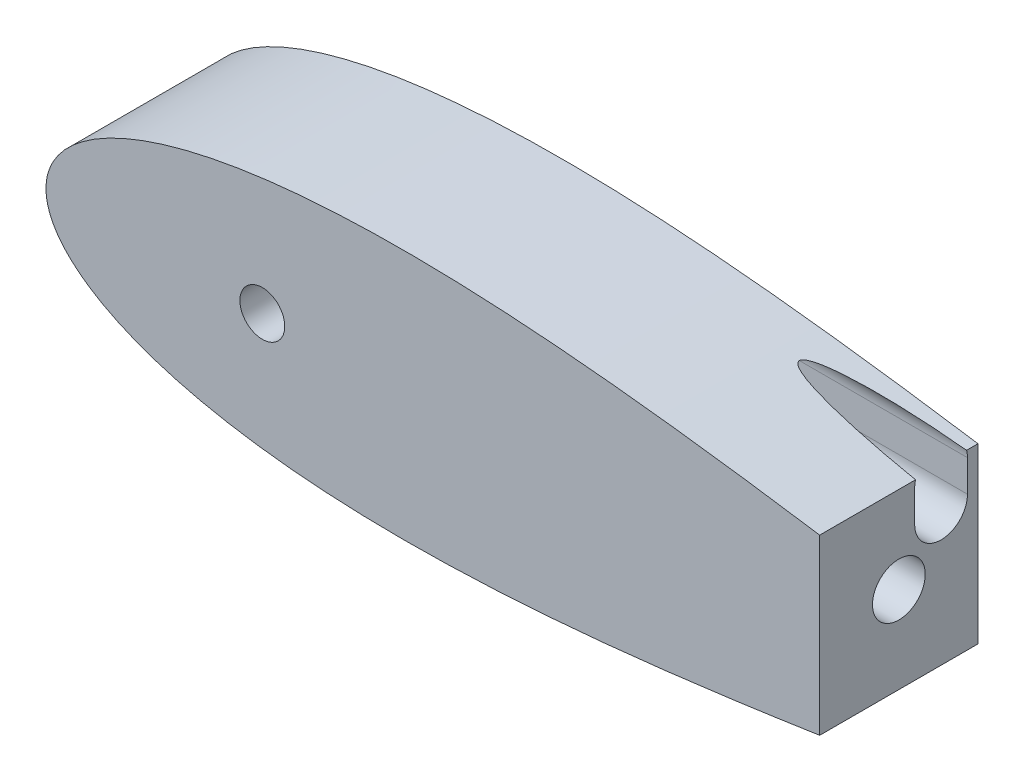
from build123d import *

# Parameters (mm, degrees)
BOSS_EXTRUDE1_DEPTH     = 76.2
SKETCH3_R               = 10.795
CUT_EXTRUDE2_DEPTH      = 76.2
SKETCH6_R               = 6.35
CUT_EXTRUDE3_DEPTH      = 53.34
CUT_EXTRUDE3_DEPTH_BACK = 0.000254
SKETCH7_R               = 1.5875
CUT_EXTRUDE4_DEPTH      = 30.48
SKETCH8_W               = 304.8
SKETCH8_H               = 127
CUT_EXTRUDE5_DEPTH      = 76.2
SKETCH9_R               = 12.7
CUT_EXTRUDE6_DEPTH      = 101.6
SKETCH10_R              = 3.175
CUT_EXTRUDE7_DEPTH      = 57.15
SKETCH11_R              = 5.08
CUT_EXTRUDE8_DEPTH      = 6.35
SKETCH12_R              = 3.175
CUT_EXTRUDE9_DEPTH      = 6.35
CUT_EXTRUDE10_DEPTH     = 198.458047838


with BuildPart() as part:
    # Sketch1 → Boss-Extrude1 (new body)
    with BuildSketch(Plane.XY):
        with BuildLine():
            Line((643.966787522, 0), (643.599082689, 0))
            Line((643.599082689, 0), (643.599082689, -1.016))
            ThreePointArc((643.599082689, -1.016), (643.872033494, -0.540245973), (643.966787522, 0))
        make_face()
        with BuildLine():
            Line((643.599082689, -1.016), (643.599082689, 0))
            Line((643.599082689, 0), (641.567082689, 0))
            ThreePointArc((641.567082689, 0), (642.269121423, -1.135922533), (643.599082689, -1.016))
        make_face()
        with BuildLine():
            Line((641.567082689, 0), (643.599082689, 0))
            Line((643.599082689, 0), (643.966787522, 0))
            ThreePointArc((643.966787522, 0), (643.547407924, 1.075012082), (642.510849283, 1.582039112))
            add(Edge.make_bspline(
                [(642.510849283, 1.582039112), (641.993392355, 1.625070631), (638.093728429, 1.953546407), (630.413817462, 2.663385493), (619.014124193, 3.849253664), (606.374988512, 5.304428983), (592.543922516, 7.037634907), (577.585454095, 9.050636147), (561.564270734, 11.338919625), (544.549749946, 13.890665375), (526.614143658, 16.687720753), (507.832591566, 19.705111663), (488.282710288, 22.911672601), (468.044367735, 26.27043606), (447.199424328, 29.739007432), (425.831595832, 33.270324121), (404.02631566, 36.813220545), (381.870662856, 40.313266856), (359.453314895, 43.713502532), (336.86454415, 46.955447457), (314.196207315, 49.979843895), (291.541767704, 52.727712704), (268.996310773, 55.141201012), (246.65655865, 57.164603829), (224.620860897, 58.745176641), (202.989192599, 59.8341217), (181.863132616, 60.387506142), (161.345829027, 60.366961324), (141.542033828, 59.739895824), (122.558104573, 58.481758104), (104.502313427, 56.574303932), (87.485018636, 54.008935199), (71.619696083, 50.784752003), (57.023709725, 46.912543066), (43.82045433, 42.41500246), (32.141645239, 37.332204029), (22.129107375, 31.731455339), (13.932423524, 25.726412106), (7.689616489, 19.513207632), (3.463136343, 13.420354421), (1.106333228, 7.923389435), (0.154611582, 3.513796615), (0, 1.007496172), (0, 0)],
                knots=[0.020157042, 0.020157042, 0.020157042, 0.020157042, 0.021270888, 0.028552555, 0.036780684, 0.045920102, 0.055931764, 0.066772884, 0.07839713, 0.090754827, 0.103793165, 0.117456432, 0.131686226, 0.146421738, 0.161599998, 0.177156133, 0.193023668, 0.209134786, 0.225420633, 0.241811602, 0.258237647, 0.274628557, 0.290914287, 0.307025229, 0.322892517, 0.338448342, 0.353626207, 0.368361232, 0.382590428, 0.396252961, 0.409290412, 0.42164701, 0.433269881, 0.444109249, 0.45411864, 0.463255055, 0.471479114, 0.478755289, 0.485052318, 0.490344026, 0.494609833, 0.497833231, 0.5, 0.5, 0.5, 0.5], degree=3))
            Line((0, 0), (27.94, 0))
            ThreePointArc((27.94, 0), (40.64, 12.7), (53.34, 0))
            Line((53.34, 0), (93.345, 0))
            ThreePointArc((93.345, 0), (104.14, 10.795), (114.935, 0))
            Line((114.935, 0), (460.660965279, 0))
            Line((460.660965279, 0), (473.360965279, 0))
            Line((473.360965279, 0), (641.567082689, 0))
        make_face()
        with BuildLine():
            ThreePointArc((642.510849283, -1.582039112), (643.111845681, -1.408373102), (643.599082689, -1.016))
            ThreePointArc((643.599082689, -1.016), (642.269121423, -1.135922533), (641.567082689, 0))
            Line((641.567082689, 0), (473.360965279, 0))
            Line((473.360965279, 0), (460.660965279, 0))
            Line((460.660965279, 0), (114.935, 0))
            ThreePointArc((114.935, 0), (104.14, -10.795), (93.345, 0))
            Line((93.345, 0), (53.34, 0))
            ThreePointArc((53.34, 0), (40.64, -12.7), (27.94, 0))
            Line((27.94, 0), (0, 0))
            add(Edge.make_bspline(
                [(0, 0), (0, -1.007496172), (0.154611582, -3.513796615), (1.106333228, -7.923389435), (3.463136343, -13.420354421), (7.689616489, -19.513207632), (13.932423524, -25.726412106), (22.129107375, -31.731455339), (32.141645239, -37.332204029), (43.82045433, -42.41500246), (57.023709725, -46.912543066), (71.619696083, -50.784752003), (87.485018636, -54.008935199), (104.502313427, -56.574303932), (122.558104573, -58.481758104), (141.542033828, -59.739895824), (161.345829027, -60.366961324), (181.863132616, -60.387506142), (202.989192599, -59.8341217), (224.620860897, -58.745176641), (246.65655865, -57.164603829), (268.996310773, -55.141201012), (291.541767704, -52.727712704), (314.196207315, -49.979843895), (336.86454415, -46.955447457), (359.453314895, -43.713502532), (381.870662856, -40.313266856), (404.02631566, -36.813220545), (425.831595832, -33.270324121), (447.199424328, -29.739007432), (468.044367735, -26.27043606), (488.282710288, -22.911672601), (507.832591566, -19.705111663), (526.614143658, -16.687720753), (544.549749946, -13.890665375), (561.564270734, -11.338919625), (577.585454095, -9.050636147), (592.543922516, -7.037634907), (606.374988512, -5.304428983), (619.014124193, -3.849253664), (630.413817462, -2.663385493), (638.093728429, -1.953546407), (641.993392355, -1.625070631), (642.510849283, -1.582039112)],
                knots=[0.5, 0.5, 0.5, 0.5, 0.502166769, 0.505390167, 0.509655974, 0.514947682, 0.521244711, 0.528520886, 0.536744945, 0.54588136, 0.555890751, 0.566730119, 0.57835299, 0.590709588, 0.603747039, 0.617409572, 0.631638768, 0.646373793, 0.661551658, 0.677107483, 0.692974771, 0.709085713, 0.725371443, 0.741762353, 0.758188398, 0.774579367, 0.790865214, 0.806976332, 0.822843867, 0.838400002, 0.853578262, 0.868313774, 0.882543568, 0.896206835, 0.909245173, 0.92160287, 0.933227116, 0.944068236, 0.954079898, 0.963219316, 0.971447445, 0.978729112, 0.979842958, 0.979842958, 0.979842958, 0.979842958], degree=3))
        make_face()
        with BuildLine():
            ThreePointArc((643.966787522, 0), (643.872033494, -0.540245973), (643.599082689, -1.016))
            ThreePointArc((643.599082689, -1.016), (643.111845681, -1.408373102), (642.510849283, -1.582039112))
            add(Edge.make_bspline(
                [(642.510849283, -1.582039112), (644.922074617, -1.381522545), (649.798936594, -1.000308437), (656.504964311, -0.543558383), (662.850933168, -0.234427605), (666.344759683, -0.054696708), (670.56, -0.015678595), (670.56, 0)],
                knots=[0.979842958, 0.979842958, 0.979842958, 0.979842958, 0.985033212, 0.990332793, 0.994605218, 0.997832222, 1, 1, 1, 1], degree=3))
            add(Edge.make_bspline(
                [(670.56, 0), (670.56, 0.015678595), (666.344759683, 0.054696708), (662.850933168, 0.234427605), (656.504964311, 0.543558383), (649.798936594, 1.000308437), (644.922074617, 1.381522545), (642.510849283, 1.582039112)],
                knots=[0, 0, 0, 0, 0.002167778, 0.005394782, 0.009667207, 0.014966788, 0.020157042, 0.020157042, 0.020157042, 0.020157042], degree=3))
            ThreePointArc((642.510849283, 1.582039112), (643.547407924, 1.075012082), (643.966787522, 0))
        make_face()
        with BuildLine():
            ThreePointArc((53.34, 0), (40.64, 12.7), (27.94, 0))
            Line((27.94, 0), (53.34, 0))
        make_face()
        with BuildLine():
            Line((53.34, 0), (27.94, 0))
            ThreePointArc((27.94, 0), (40.64, -12.7), (53.34, 0))
        make_face()
        with BuildLine():
            ThreePointArc((93.345, 0), (104.14, -10.795), (114.935, 0))
            Line((114.935, 0), (93.345, 0))
        make_face()
        with BuildLine():
            Line((93.345, 0), (114.935, 0))
            ThreePointArc((114.935, 0), (104.14, 10.795), (93.345, 0))
        make_face()
    extrude(amount=BOSS_EXTRUDE1_DEPTH)

    # Sketch3 → Cut-Extrude2 (cut)
    with BuildSketch(Plane.XY.offset(76.2)):
        with Locations((104.139232412, 0)):
            Circle(SKETCH3_R)
    extrude(amount=-CUT_EXTRUDE2_DEPTH, mode=Mode.SUBTRACT)

    # Sketch6 → Cut-Extrude3 (cut, two sides)
    with BuildSketch(Plane(origin=(0, 0, 0), x_dir=(0, 0, -1), z_dir=(1, 0, 0))) as cut_extrude3_sk:
        with Locations((-20.32, 0)):
            Circle(SKETCH6_R)
    extrude(amount=CUT_EXTRUDE3_DEPTH, mode=Mode.SUBTRACT)
    extrude(cut_extrude3_sk.sketch, amount=-CUT_EXTRUDE3_DEPTH_BACK, mode=Mode.SUBTRACT)

    # Sketch7 → Cut-Extrude4 (cut)
    with BuildSketch(Plane(origin=(0, 0, 0), x_dir=(-1, 0, 0), z_dir=(0, 0, -1))):
        with Locations((-38.1, 0)):
            Circle(SKETCH7_R)
        with Locations((-50.8, 0)):
            Circle(SKETCH7_R)
    extrude(amount=-CUT_EXTRUDE4_DEPTH, mode=Mode.SUBTRACT)

    # Sketch8 → Cut-Extrude5 (cut)
    with BuildSketch(Plane(origin=(0, 0, 0), x_dir=(-1, 0, 0), z_dir=(0, 0, -1))):
        with Locations((-524.843319628, 0.490119432)):
            Rectangle(SKETCH8_W, SKETCH8_H)
    extrude(amount=-CUT_EXTRUDE5_DEPTH, mode=Mode.SUBTRACT)

    # Sketch9 → Cut-Extrude6 (cut)
    with BuildSketch(Plane(origin=(372.443319628, 0, 0), x_dir=(0, 0, -1), z_dir=(1, 0, 0))):
        with Locations((-38.1, 0)):
            Circle(SKETCH9_R)
    extrude(amount=-CUT_EXTRUDE6_DEPTH, mode=Mode.SUBTRACT)

    # Sketch10 → Cut-Extrude7 (cut)
    with BuildSketch(Plane(origin=(0, 0, 0), x_dir=(-1, 0, 0), z_dir=(0, 0, -1))):
        with Locations((-343.868319647, 0)):
            Circle(SKETCH10_R)
        with Locations((-286.718319647, 0)):
            Circle(SKETCH10_R)
    extrude(amount=-CUT_EXTRUDE7_DEPTH, mode=Mode.SUBTRACT)

    # Sketch11 → Cut-Extrude8 (cut)
    with BuildSketch(Plane(origin=(0, 0, 0), x_dir=(-1, 0, 0), z_dir=(0, 0, -1))):
        with Locations((-286.718319647, 0)):
            Circle(SKETCH11_R)
        with Locations((-343.868319647, 0)):
            Circle(SKETCH11_R)
    extrude(amount=-CUT_EXTRUDE8_DEPTH, mode=Mode.SUBTRACT)

    # Sketch12 → Cut-Extrude9 (cut)
    with BuildSketch(Plane(origin=(0, 0, 0), x_dir=(-1, 0, 0), z_dir=(0, 0, -1))):
        with Locations((-38.1, 0)):
            Circle(SKETCH12_R)
        with Locations((-50.8, 0)):
            Circle(SKETCH12_R)
    extrude(amount=-CUT_EXTRUDE9_DEPTH, mode=Mode.SUBTRACT)

    # Sketch13 → Cut-Extrude10 (cut)
    with BuildSketch(Plane(origin=(372.443319628, 0, 0), x_dir=(0, 0, -1), z_dir=(1, 0, 0))):
        with BuildLine():
            Line((-30.48, 23.232341673), (-30.48, 38.472341673))
            ThreePointArc((-30.48, 38.472341673), (-17.78, 51.172341673), (-5.08, 38.472341673))
            Line((-5.08, 38.472341673), (-5.08, 23.232341673))
            ThreePointArc((-5.08, 23.232341673), (-17.78, 10.532341673), (-30.48, 23.232341673))
        make_face()
    extrude(amount=-CUT_EXTRUDE10_DEPTH, mode=Mode.SUBTRACT)


solid = part.part
